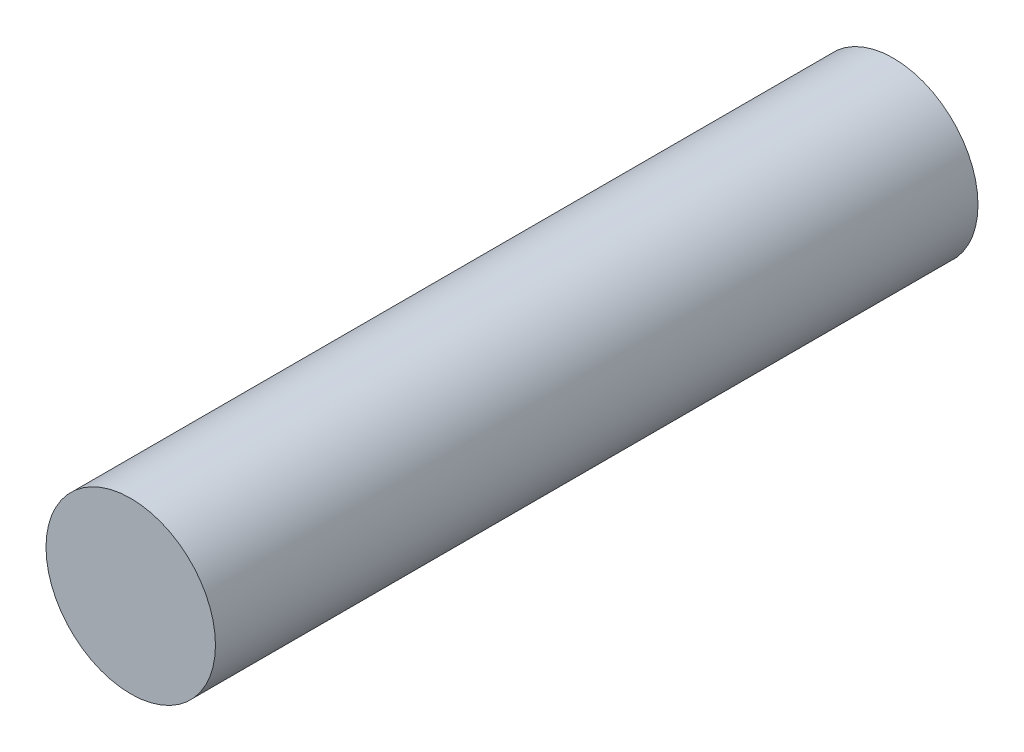
from build123d import *

# Parameters (mm, degrees)
CROQUIS1_R              = 2
SALIENTE_EXTRUIR1_DEPTH = 18


with BuildPart() as part:
    # Croquis1 → Saliente-Extruir1 (new body)
    with BuildSketch(Plane.XY):
        Circle(CROQUIS1_R)
    extrude(amount=SALIENTE_EXTRUIR1_DEPTH)


solid = part.part
